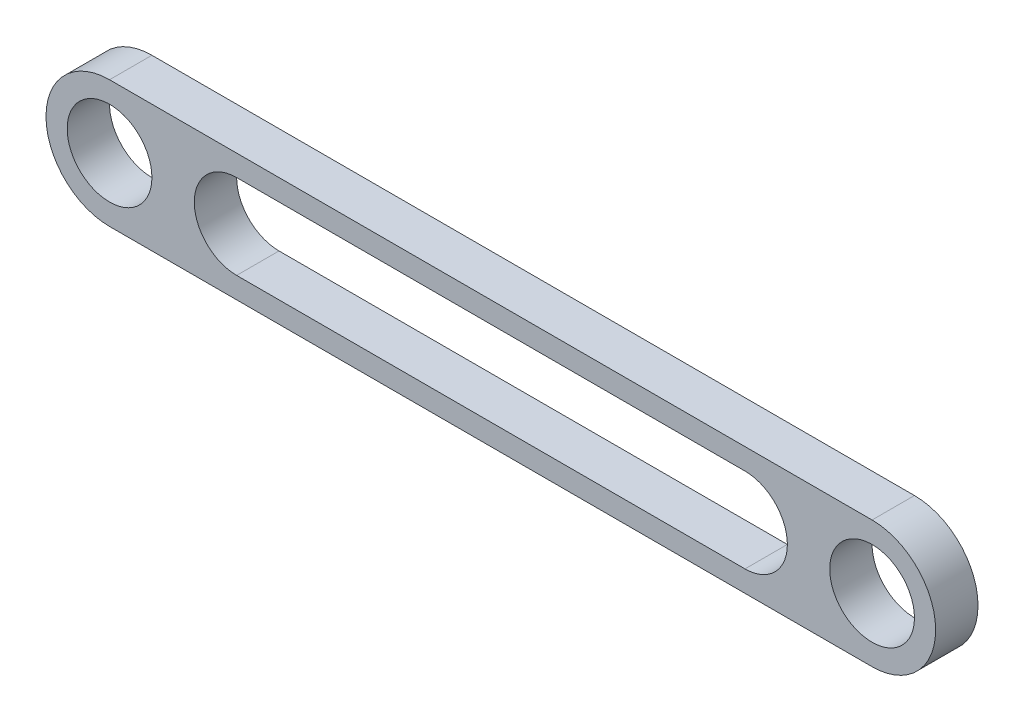
from build123d import *

# Parameters (mm, degrees)
SKETCH2_R           = 10
BOSS_EXTRUDE1_DEPTH = 10


with BuildPart() as part:
    # Sketch2 → Boss-Extrude1 (new body)
    with BuildSketch(Plane.XY):
        with BuildLine():
            Line((0, 15), (180, 15))
            ThreePointArc((180, 15), (195, 0), (180, -15))
            Line((180, -15), (0, -15))
            ThreePointArc((0, -15), (-15, 0), (0, 15))
        make_face()
        Circle(SKETCH2_R, mode=Mode.SUBTRACT)
        with Locations((180, 0)):
            Circle(SKETCH2_R, mode=Mode.SUBTRACT)
        with BuildLine():
            Line((30, 10), (150, 10))
            ThreePointArc((150, 10), (160, 0), (150, -10))
            Line((150, -10), (30, -10))
            ThreePointArc((30, -10), (20, 0), (30, 10))
        make_face(mode=Mode.SUBTRACT)
    extrude(amount=BOSS_EXTRUDE1_DEPTH)


solid = part.part
